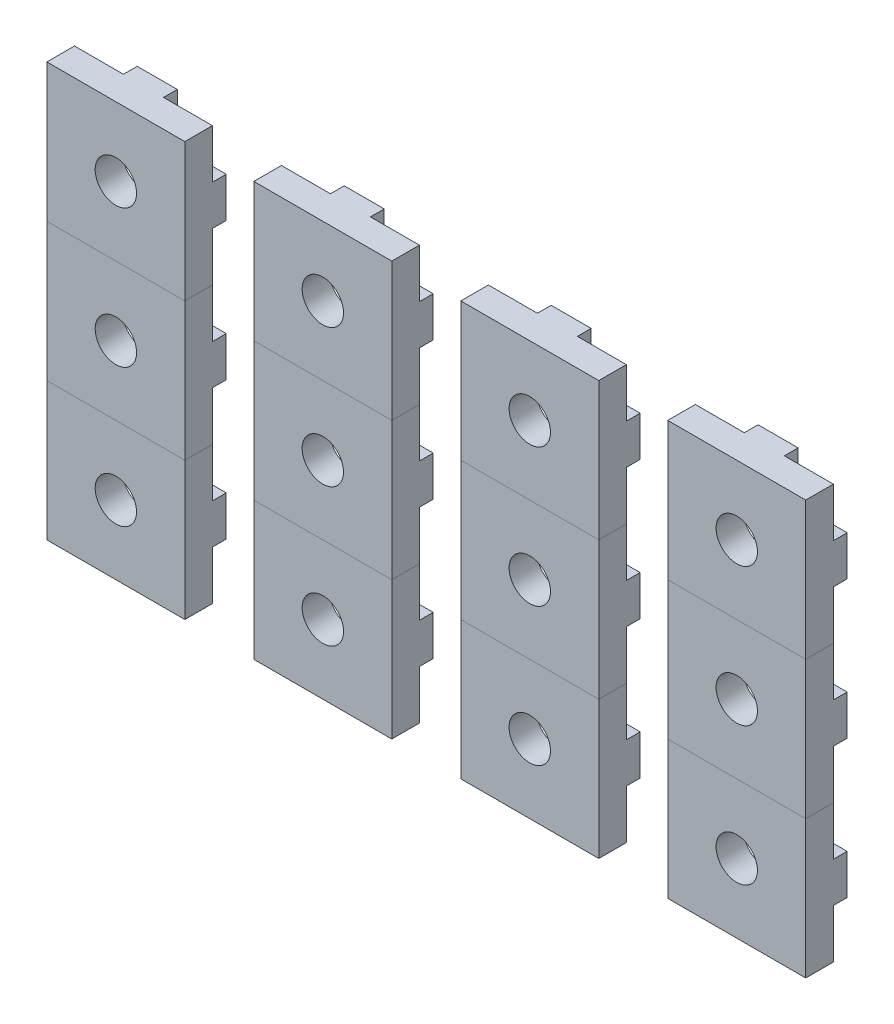
from build123d import *

# Parameters (mm, degrees)
SKETCH1_W                = 10
SKETCH1_H                = 10
SKETCH1_R                = 1.5
MAIN_DEPTH               = 2
ANTIROTATIONSYSTEM_DEPTH = 1
CIRPATTERN1_COUNT        = 4
LPATTERN1_COUNT          = 3
LPATTERN1_PITCH          = 10
LPATTERN2_COUNT          = 4
LPATTERN2_PITCH          = 15


with BuildPart() as part:
    # Sketch1 → Main (new body)
    with BuildSketch(Plane.XY):
        Rectangle(SKETCH1_W, SKETCH1_H)
        Circle(SKETCH1_R, mode=Mode.SUBTRACT)
    extrude(amount=MAIN_DEPTH)

    # Sketch2 → AntiRotationSystem (add)
    with BuildSketch(Plane(origin=(0, 0, 0), x_dir=(-1, 0, 0), z_dir=(0, 0, -1))):
        Polygon((-5, 1.45), (-3.9, 1.45), (-3.9, 3), (-2.1, 0.95), (-2.1, -0.95), (-3.9, -3), (-3.9, -1.45), (-5, -1.45), align=None)
    antirotationsystem = extrude(amount=ANTIROTATIONSYSTEM_DEPTH)

    # CirPattern1: AntiRotationSystem ×4 about axis
    cirpattern1_axis = Axis((0, 0, 0), (0, 0, 1))
    for i in range(1, CIRPATTERN1_COUNT):
        add(antirotationsystem.rotate(cirpattern1_axis, i * 360 / CIRPATTERN1_COUNT))


with BuildPart() as lpattern1_1:
    # LPattern1: pattern copy
    add(part.part.moved(Location(Vector(0, -1, 0) * (1 * LPATTERN1_PITCH))))


with BuildPart() as lpattern1_2:
    # LPattern1: pattern copy
    add(part.part.moved(Location(Vector(0, -1, 0) * (2 * LPATTERN1_PITCH))))


with BuildPart() as lpattern2_1:
    # LPattern2: pattern copy
    add(part.part.moved(Location(Vector(-1, 0, 0) * (1 * LPATTERN2_PITCH))))


with BuildPart() as lpattern2_2:
    # LPattern2: pattern copy
    add(part.part.moved(Location(Vector(-1, 0, 0) * (2 * LPATTERN2_PITCH))))


with BuildPart() as lpattern2_3:
    # LPattern2: pattern copy
    add(part.part.moved(Location(Vector(-1, 0, 0) * (3 * LPATTERN2_PITCH))))


with BuildPart() as lpattern2_4:
    # LPattern2: pattern copy
    add(lpattern1_1.part.moved(Location(Vector(-1, 0, 0) * (1 * LPATTERN2_PITCH))))


with BuildPart() as lpattern2_5:
    # LPattern2: pattern copy
    add(lpattern1_1.part.moved(Location(Vector(-1, 0, 0) * (2 * LPATTERN2_PITCH))))


with BuildPart() as lpattern2_6:
    # LPattern2: pattern copy
    add(lpattern1_1.part.moved(Location(Vector(-1, 0, 0) * (3 * LPATTERN2_PITCH))))


with BuildPart() as lpattern2_7:
    # LPattern2: pattern copy
    add(lpattern1_2.part.moved(Location(Vector(-1, 0, 0) * (1 * LPATTERN2_PITCH))))


with BuildPart() as lpattern2_8:
    # LPattern2: pattern copy
    add(lpattern1_2.part.moved(Location(Vector(-1, 0, 0) * (2 * LPATTERN2_PITCH))))


with BuildPart() as lpattern2_9:
    # LPattern2: pattern copy
    add(lpattern1_2.part.moved(Location(Vector(-1, 0, 0) * (3 * LPATTERN2_PITCH))))


solid = Compound([part.part, lpattern1_1.part, lpattern1_2.part, lpattern2_1.part, lpattern2_2.part, lpattern2_3.part, lpattern2_4.part, lpattern2_5.part, lpattern2_6.part, lpattern2_7.part, lpattern2_8.part, lpattern2_9.part])
